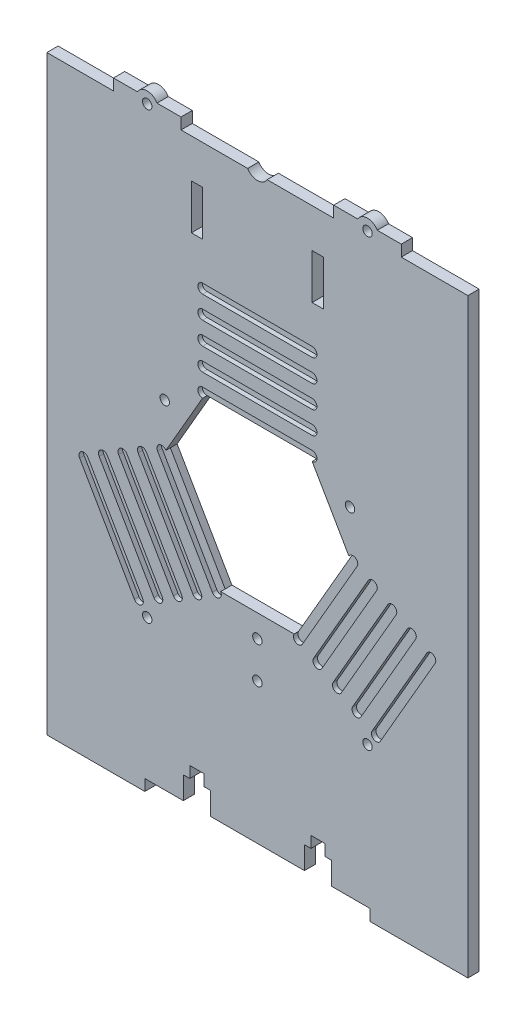
from build123d import *

# Parameters (mm, degrees)
SKETCH1_W           = 187
SKETCH1_H           = 262.5
BOSS_EXTRUDE1_DEPTH = 5
SKETCH2_R           = 5
SKETCH2_W           = 100
SKETCH2_H           = 5
CUT_EXTRUDE1_DEPTH  = 5
BOSS_EXTRUDE2_DEPTH = 5
SKETCH3_R           = 2.1
CUT_EXTRUDE2_DEPTH  = 5
CUT_EXTRUDE3_DEPTH  = 2
CUT_EXTRUDE4_DEPTH  = 6
SKETCH8_R           = 2.1
SKETCH8_W           = 5
SKETCH8_H           = 20
CUT_EXTRUDE5_DEPTH  = 10


with BuildPart() as part:
    # Sketch1 → Boss-Extrude1 (new body)
    with BuildSketch(Plane.XY):
        Rectangle(SKETCH1_W, SKETCH1_H)
    extrude(amount=BOSS_EXTRUDE1_DEPTH)

    # Sketch2 → Cut-Extrude1 (cut)
    with BuildSketch(Plane.XY.offset(5)):
        with Locations((0, 133.75)):
            Circle(SKETCH2_R)
        with Locations((0, -128.75)):
            Rectangle(SKETCH2_W, SKETCH2_H)
    extrude(amount=-CUT_EXTRUDE1_DEPTH, mode=Mode.SUBTRACT)

    # Sketch4 → Boss-Extrude2 (add)
    with BuildSketch(Plane.XY.offset(5)):
        with BuildLine():
            Line((33.915063509, 136.25), (44.584936491, 136.25))
            ThreePointArc((44.584936491, 136.25), (48.915063509, 138.75), (53.245190528, 136.25))
            Line((53.245190528, 136.25), (63.915063509, 136.25))
            Line((63.915063509, 136.25), (63.915063509, 131.25))
            Line((63.915063509, 131.25), (33.915063509, 131.25))
            Line((33.915063509, 131.25), (33.915063509, 136.25))
        make_face()
        with BuildLine():
            Line((-53.245190528, 136.25), (-63.915063509, 136.25))
            Line((-63.915063509, 136.25), (-63.915063509, 131.25))
            Line((-63.915063509, 131.25), (-33.915063509, 131.25))
            Line((-33.915063509, 131.25), (-33.915063509, 136.25))
            Line((-33.915063509, 136.25), (-44.584936491, 136.25))
            ThreePointArc((-44.584936491, 136.25), (-48.915063509, 138.75), (-53.245190528, 136.25))
        make_face()
    extrude(amount=-BOSS_EXTRUDE2_DEPTH)

    # Sketch3 → Cut-Extrude2 (cut)
    with BuildSketch(Plane.XY.offset(5)):
        with Locations((-48.915063509, 133.75)):
            Circle(SKETCH3_R)
        with Locations((48.915063509, 133.75)):
            Circle(SKETCH3_R)
        with Locations((-48.915063509, -63.75)):
            Circle(SKETCH3_R)
        with Locations((0, -63.75)):
            Circle(SKETCH3_R)
        with Locations((48.915063509, -63.75)):
            Circle(SKETCH3_R)
        Polygon((-32.90655119, -126.25), (-32.90655119, -116.25), (-30.00655119, -116.25), (-30.00655119, -111.25), (-23.80655119, -111.25), (-23.80655119, -116.25), (-20.90655119, -116.25), (-20.90655119, -126.25), align=None)
        Polygon((32.90655119, -126.25), (20.90655119, -126.25), (20.90655119, -116.25), (23.80655119, -116.25), (23.80655119, -111.25), (30.00655119, -111.25), (30.00655119, -116.25), (32.90655119, -116.25), align=None)
    extrude(amount=-CUT_EXTRUDE2_DEPTH, mode=Mode.SUBTRACT)

    # Sketch5 → Cut-Extrude3 (cut)
    with BuildSketch(Plane.XY.offset(5)):
        with BuildLine():
            Line((-24.33400194, 77.119068048), (24.33400194, 77.119068048))
            ThreePointArc((24.33400194, 77.119068048), (26.453069989, 75), (24.33400194, 72.880931952))
            Line((24.33400194, 72.880931952), (-24.33400194, 72.880931952))
            ThreePointArc((-24.33400194, 72.880931952), (-26.453069989, 75), (-24.33400194, 77.119068048))
        make_face()
        with BuildLine():
            Line((-24.33400194, 67.119068048), (24.33400194, 67.119068048))
            ThreePointArc((24.33400194, 67.119068048), (26.453069989, 65), (24.33400194, 62.880931952))
            Line((24.33400194, 62.880931952), (-24.33400194, 62.880931952))
            ThreePointArc((-24.33400194, 62.880931952), (-26.453069989, 65), (-24.33400194, 67.119068048))
        make_face()
        with BuildLine():
            Line((-24.33400194, 57.119068048), (24.33400194, 57.119068048))
            ThreePointArc((24.33400194, 57.119068048), (26.453069989, 55), (24.33400194, 52.880931952))
            Line((24.33400194, 52.880931952), (-24.33400194, 52.880931952))
            ThreePointArc((-24.33400194, 52.880931952), (-26.453069989, 55), (-24.33400194, 57.119068048))
        make_face()
        with BuildLine():
            Line((-24.33400194, 47.119068048), (24.33400194, 47.119068048))
            ThreePointArc((24.33400194, 47.119068048), (26.453069989, 45), (24.33400194, 42.880931952))
            Line((24.33400194, 42.880931952), (-24.33400194, 42.880931952))
            ThreePointArc((-24.33400194, 42.880931952), (-26.453069989, 45), (-24.33400194, 47.119068048))
        make_face()
        with BuildLine():
            Line((-24.33400194, 37.119068048), (24.33400194, 37.119068048))
            ThreePointArc((24.33400194, 37.119068048), (26.453069989, 35), (24.33400194, 32.880931952))
            Line((24.33400194, 32.880931952), (-24.33400194, 32.880931952))
            ThreePointArc((-24.33400194, 32.880931952), (-26.453069989, 35), (-24.33400194, 37.119068048))
        make_face()
        with BuildLine():
            Line((-24.33400194, 27.119068048), (24.33400194, 27.119068048))
            ThreePointArc((24.33400194, 27.119068048), (26.453069989, 25), (24.33400194, 22.880931952))
            Line((24.33400194, 22.880931952), (-24.33400194, 22.880931952))
            ThreePointArc((-24.33400194, 22.880931952), (-26.453069989, 25), (-24.33400194, 27.119068048))
        make_face()
        with BuildLine():
            Line((78.954073016, -17.485670168), (54.620071076, -59.63339788))
            ThreePointArc((54.620071076, -59.63339788), (51.72537029, -60.409030618), (50.949737551, -57.514329832))
            Line((50.949737551, -57.514329832), (75.283739492, -15.36660212))
            ThreePointArc((75.283739492, -15.36660212), (78.178440278, -14.590969382), (78.954073016, -17.485670168))
        make_face()
        with BuildLine():
            Line((70.293818978, -12.485670168), (45.959817038, -54.63339788))
            ThreePointArc((45.959817038, -54.63339788), (43.065116252, -55.409030618), (42.289483514, -52.514329832))
            Line((42.289483514, -52.514329832), (66.623485454, -10.36660212))
            ThreePointArc((66.623485454, -10.36660212), (69.51818624, -9.590969382), (70.293818978, -12.485670168))
        make_face()
        with BuildLine():
            Line((61.633564941, -7.485670168), (37.299563, -49.63339788))
            ThreePointArc((37.299563, -49.63339788), (34.404862214, -50.409030618), (33.629229476, -47.514329832))
            Line((33.629229476, -47.514329832), (57.963231416, -5.36660212))
            ThreePointArc((57.963231416, -5.36660212), (60.857932202, -4.590969382), (61.633564941, -7.485670168))
        make_face()
        with BuildLine():
            Line((52.973310903, -2.485670168), (28.639308963, -44.63339788))
            ThreePointArc((28.639308963, -44.63339788), (25.744608176, -45.409030618), (24.968975438, -42.514329832))
            Line((24.968975438, -42.514329832), (49.302977378, -0.36660212))
            ThreePointArc((49.302977378, -0.36660212), (52.197678165, 0.409030618), (52.973310903, -2.485670168))
        make_face()
        with BuildLine():
            Line((44.313056865, 2.514329832), (19.979054925, -39.63339788))
            ThreePointArc((19.979054925, -39.63339788), (17.084354138, -40.409030618), (16.3087214, -37.514329832))
            Line((16.3087214, -37.514329832), (40.64272334, 4.63339788))
            ThreePointArc((40.64272334, 4.63339788), (43.537424127, 5.409030618), (44.313056865, 2.514329832))
        make_face()
        with BuildLine():
            Line((35.652802827, 7.514329832), (11.318800887, -34.63339788))
            ThreePointArc((11.318800887, -34.63339788), (8.4241001, -35.409030618), (7.648467362, -32.514329832))
            Line((7.648467362, -32.514329832), (31.982469302, 9.63339788))
            ThreePointArc((31.982469302, 9.63339788), (34.877170089, 10.409030618), (35.652802827, 7.514329832))
        make_face()
        with BuildLine():
            Line((-54.620071076, -59.63339788), (-78.954073016, -17.485670168))
            ThreePointArc((-78.954073016, -17.485670168), (-78.178440278, -14.590969382), (-75.283739492, -15.36660212))
            Line((-75.283739492, -15.36660212), (-50.949737551, -57.514329832))
            ThreePointArc((-50.949737551, -57.514329832), (-51.72537029, -60.409030618), (-54.620071076, -59.63339788))
        make_face()
        with BuildLine():
            Line((-45.959817038, -54.63339788), (-70.293818978, -12.485670168))
            ThreePointArc((-70.293818978, -12.485670168), (-69.51818624, -9.590969382), (-66.623485454, -10.36660212))
            Line((-66.623485454, -10.36660212), (-42.289483514, -52.514329832))
            ThreePointArc((-42.289483514, -52.514329832), (-43.065116252, -55.409030618), (-45.959817038, -54.63339788))
        make_face()
        with BuildLine():
            Line((-37.299563, -49.63339788), (-61.633564941, -7.485670168))
            ThreePointArc((-61.633564941, -7.485670168), (-60.857932202, -4.590969382), (-57.963231416, -5.36660212))
            Line((-57.963231416, -5.36660212), (-33.629229476, -47.514329832))
            ThreePointArc((-33.629229476, -47.514329832), (-34.404862214, -50.409030618), (-37.299563, -49.63339788))
        make_face()
        with BuildLine():
            Line((-28.639308963, -44.63339788), (-52.973310903, -2.485670168))
            ThreePointArc((-52.973310903, -2.485670168), (-52.197678165, 0.409030618), (-49.302977378, -0.36660212))
            Line((-49.302977378, -0.36660212), (-24.968975438, -42.514329832))
            ThreePointArc((-24.968975438, -42.514329832), (-25.744608176, -45.409030618), (-28.639308963, -44.63339788))
        make_face()
        with BuildLine():
            Line((-19.979054925, -39.63339788), (-44.313056865, 2.514329832))
            ThreePointArc((-44.313056865, 2.514329832), (-43.537424127, 5.409030618), (-40.64272334, 4.63339788))
            Line((-40.64272334, 4.63339788), (-16.3087214, -37.514329832))
            ThreePointArc((-16.3087214, -37.514329832), (-17.084354138, -40.409030618), (-19.979054925, -39.63339788))
        make_face()
        with BuildLine():
            Line((-11.318800887, -34.63339788), (-35.652802827, 7.514329832))
            ThreePointArc((-35.652802827, 7.514329832), (-34.877170089, 10.409030618), (-31.982469302, 9.63339788))
            Line((-31.982469302, 9.63339788), (-7.648467362, -32.514329832))
            ThreePointArc((-7.648467362, -32.514329832), (-8.4241001, -35.409030618), (-11.318800887, -34.63339788))
        make_face()
    extrude(amount=-CUT_EXTRUDE3_DEPTH, mode=Mode.SUBTRACT)

    # Sketch6 → Cut-Extrude4 (cut, through all)
    with BuildSketch(Plane.XY.offset(5)):
        Polygon((-24.33400194, 32.880931952), (24.33400194, 32.880931952), (40.64272334, 4.63339788), (16.3087214, -37.514329832), (-16.3087214, -37.514329832), (-40.64272334, 4.63339788), align=None)
    extrude(amount=-CUT_EXTRUDE4_DEPTH, mode=Mode.SUBTRACT)

    # Sketch8 → Cut-Extrude5 (cut)
    with BuildSketch(Plane.XY.offset(5)):
        with Locations((0, -47.514329832)):
            Circle(SKETCH8_R)
        with Locations((-41.148616678, 23.757164916)):
            Circle(SKETCH8_R)
        with Locations((41.148616678, 23.757164916)):
            Circle(SKETCH8_R)
        with Locations((-26.806655169, 103.979066034)):
            Rectangle(SKETCH8_W, SKETCH8_H)
        with Locations((26.806655169, 103.979066034)):
            Rectangle(SKETCH8_W, SKETCH8_H)
    extrude(amount=-CUT_EXTRUDE5_DEPTH, mode=Mode.SUBTRACT)


solid = part.part
